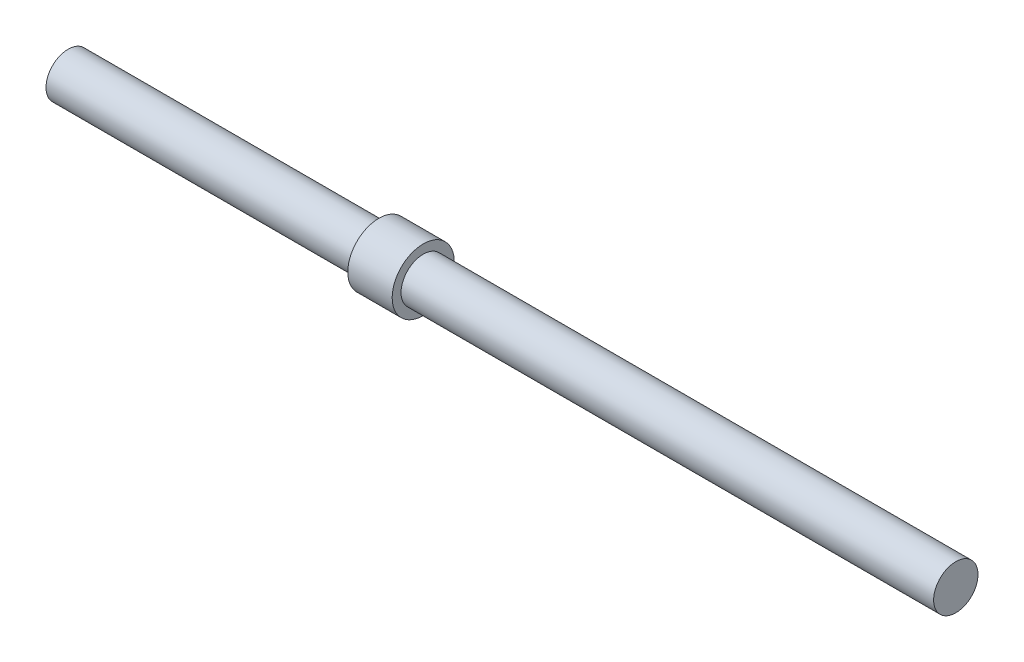
from build123d import *

# Parameters (mm, degrees)
SKETCH1_R           = 5
BOSS_EXTRUDE1_DEPTH = 100
BOSS_EXTRUDE2_START = -70
SKETCH2_R           = 7
BOSS_EXTRUDE2_DEPTH = 10


with BuildPart() as part:
    # Sketch1 → Boss-Extrude1 (new body, symmetric)
    with BuildSketch(Plane(origin=(0, 0, 0), x_dir=(0, 0, -1), z_dir=(1, 0, 0))):
        Circle(SKETCH1_R)
    extrude(amount=BOSS_EXTRUDE1_DEPTH, both=True)

    # Sketch2 → Boss-Extrude2 (add)
    with BuildSketch(Plane.ZY.offset(100).offset(BOSS_EXTRUDE2_START)):
        Circle(SKETCH2_R)
    extrude(amount=-BOSS_EXTRUDE2_DEPTH)


solid = part.part
